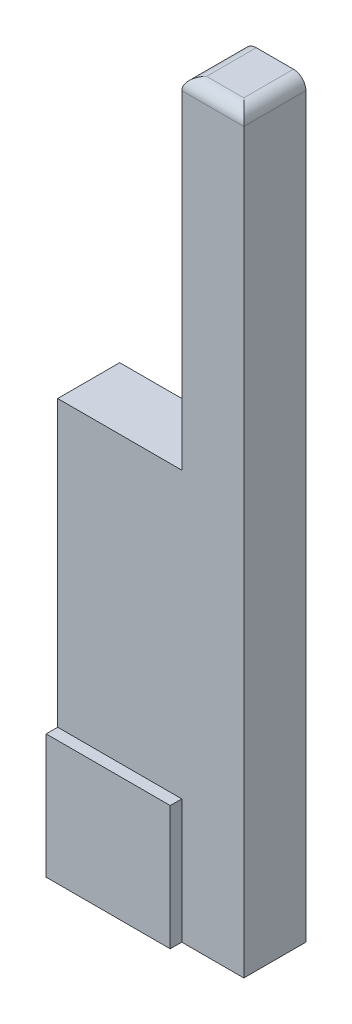
from build123d import *

# Parameters (mm, degrees)
BOSS_EXTRUDE1_DEPTH = 5
SKETCH2_W           = 10
SKETCH2_H           = 10
BOSS_EXTRUDE2_DEPTH = 5.93
FILLET1_R           = 1
SKETCH3_R           = 1.029396526
CUT_EXTRUDE1_DEPTH  = 0.5


with BuildPart() as part:
    # Sketch1 → Boss-Extrude1 (new body)
    with BuildSketch(Plane.XY):
        Polygon((10, 12), (10, -15.48), (0, -15.48), (0, -48.42), (15, -48.42), (15, 12), align=None)
    extrude(amount=BOSS_EXTRUDE1_DEPTH)

    # Sketch2 → Boss-Extrude2 (add)
    with BuildSketch(Plane(origin=(0, 0, 0), x_dir=(-1, 0, 0), z_dir=(0, 0, -1))):
        with Locations((-5, -43.42)):
            Rectangle(SKETCH2_W, SKETCH2_H)
    extrude(amount=-BOSS_EXTRUDE2_DEPTH)

    # Fillet1
    fillet1_edges = [part.edges().sort_by_distance(p)[0] for p in [
        (10, 12, 2.5),
        (15, 12, 2.5),
        (12.5, 12, 5),
    ]]
    fillet(fillet1_edges, radius=FILLET1_R)

    # Sketch3 → Cut-Extrude1 (cut)
    with BuildSketch(Plane.XZ.offset(48.42)):
        with Locations((12.5, 2.5)):
            Circle(SKETCH3_R)
    extrude(amount=-CUT_EXTRUDE1_DEPTH, mode=Mode.SUBTRACT)


solid = part.part
